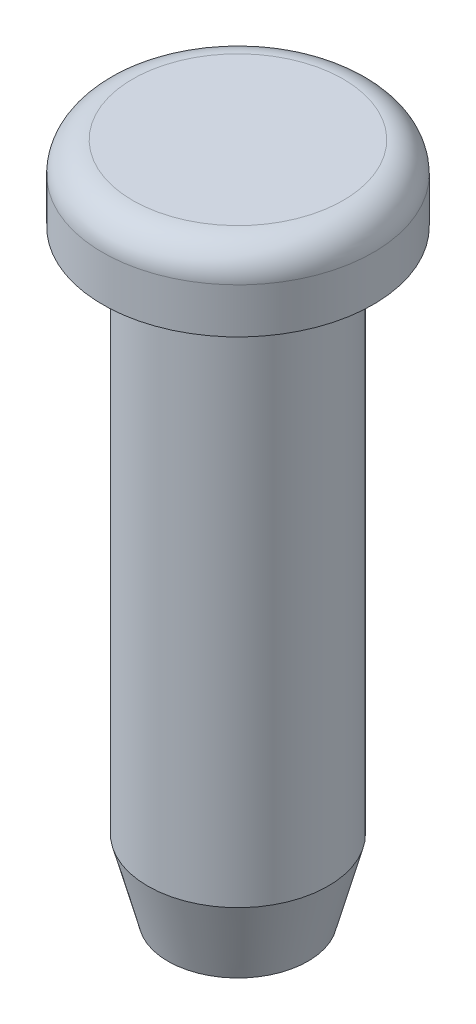
from build123d import *

# Parameters (mm, degrees)
SKETCH1_R           = 1.524
BOSS_EXTRUDE1_DEPTH = 5.08
CHAMFER1_SIZE       = 1.27
CHAMFER1_SIZE2      = 0.340295474


with BuildPart() as part:
    # Sketch1 → Boss-Extrude1 (new body, symmetric)
    with BuildSketch(Plane(origin=(0, 0, 0), x_dir=(1, 0, 0), z_dir=(0, 1, 0))):
        Circle(SKETCH1_R)
    extrude(amount=BOSS_EXTRUDE1_DEPTH, both=True)

    # Chamfer1
    chamfer1_edges = [part.edges().sort_by_distance(p)[0] for p in [
        (-1.524, -5.08, 0),
    ]]
    chamfer1_side = [part.faces().sort_by_distance(p)[0] for p in [
        (-1.524, 0, 0),
    ]]
    chamfer(chamfer1_edges, length=CHAMFER1_SIZE, length2=CHAMFER1_SIZE2, reference=chamfer1_side[0])

    # Sketch2 → Revolve1 (revolve)
    with BuildSketch(Plane.XY):
        with BuildLine():
            Line((0, 5.08), (2.286, 5.08))
            Line((2.286, 5.08), (2.286, 5.842))
            ThreePointArc((2.286, 5.842), (2.137210245, 6.201210245), (1.778, 6.35))
            Line((1.778, 6.35), (0, 6.35))
            Line((0, 6.35), (0, 5.08))
        make_face()
    revolve(axis=Axis((0, 5.08, 0), (0, 1, 0)))


solid = part.part
